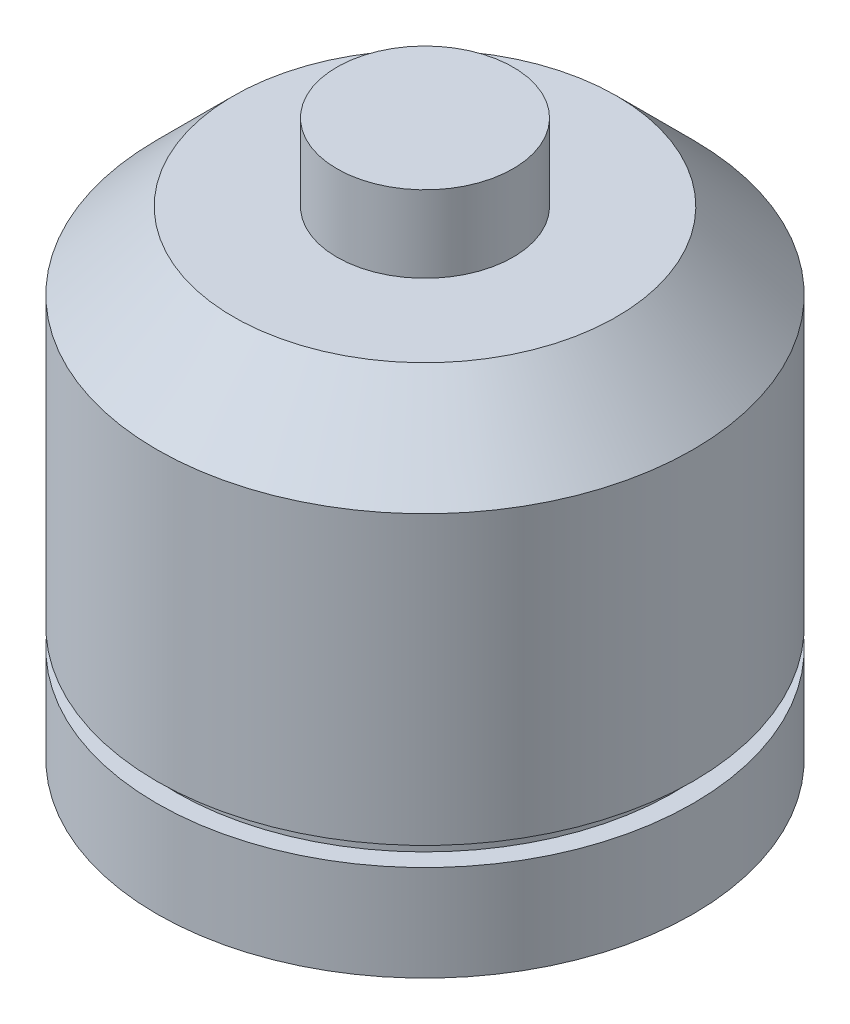
from build123d import *

# Parameters (mm, degrees)
CHAMFER1_SIZE = 4


with BuildPart() as part:
    # Sketch1 → Revolve1 (revolve)
    with BuildSketch(Plane(origin=(0, 0, 0), x_dir=(0, 0, -1), z_dir=(1, 0, 0))):
        Polygon((14, 12.175), (4.6, 12.175), (4.6, 16.175), (0, 16.175), (0, 12.175), (0, -12.825), (14, -12.825), (14, -7.825), (13, -7.825), (13, -6.825), (14, -6.825), align=None)
    revolve(axis=Axis((0, 12.175, 0), (0, -1, 0)))

    # Chamfer1
    chamfer1_edges = [part.edges().sort_by_distance(p)[0] for p in [
        (0, 12.175, 14),
    ]]
    chamfer(chamfer1_edges, length=CHAMFER1_SIZE)


solid = part.part
